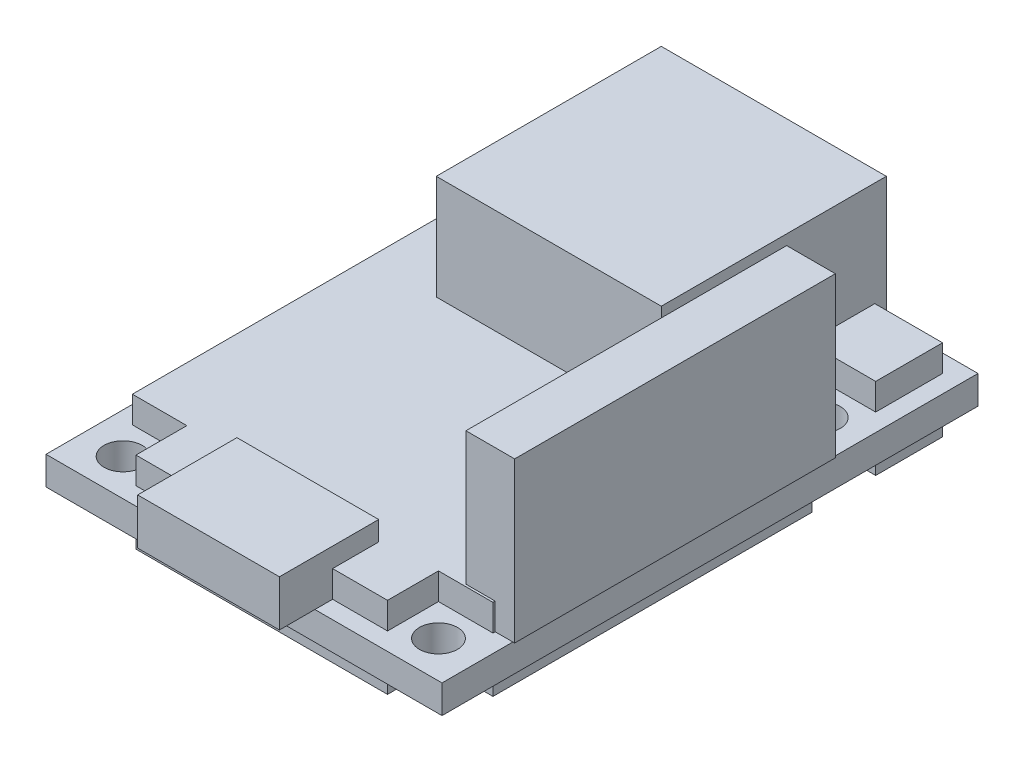
from build123d import *

# Parameters (mm, degrees)
SKETCH1_W               = 22.35
SKETCH1_H               = 30.25
BOSS_EXTRUDE1_DEPTH     = 0.8
SKETCH2_R               = 1.075
CUT_EXTRUDE1_DEPTH      = 1.8
CUT_EXTRUDE1_DEPTH_BACK = 1.8
BOSS_EXTRUDE2_DEPTH     = 2.3
SKETCH4_W               = 8
SKETCH4_H               = 5.6
BOSS_EXTRUDE3_DEPTH     = 2.6
SKETCH5_W               = 12.7
SKETCH5_H               = 12.7
BOSS_EXTRUDE4_DEPTH     = 7.4
SKETCH6_W               = 2.75
SKETCH6_H               = 18.1
BOSS_EXTRUDE5_DEPTH     = 9


with BuildPart() as part:
    # Sketch1 → Boss-Extrude1 (new body, symmetric)
    with BuildSketch(Plane(origin=(0, 0, 0), x_dir=(1, 0, 0), z_dir=(0, 1, 0))):
        Rectangle(SKETCH1_W, SKETCH1_H)
    extrude(amount=BOSS_EXTRUDE1_DEPTH, both=True)

    # Sketch2 → Cut-Extrude1 (cut, two sides)
    with BuildSketch(Plane(origin=(0, 0, 0), x_dir=(1, 0, 0), z_dir=(0, 1, 0))) as cut_extrude1_sk:
        with Locations((8.9, 8.55)):
            Circle(SKETCH2_R)
        with Locations((8.9, -13.05)):
            Circle(SKETCH2_R)
        with Locations((-8.9, 8.55)):
            Circle(SKETCH2_R)
        with Locations((-8.9, -13.05)):
            Circle(SKETCH2_R)
    extrude(amount=CUT_EXTRUDE1_DEPTH, mode=Mode.SUBTRACT)
    extrude(cut_extrude1_sk.sketch, amount=-CUT_EXTRUDE1_DEPTH_BACK, mode=Mode.SUBTRACT)

    # Sketch3 → Boss-Extrude2 (add, symmetric)
    with BuildSketch(Plane(origin=(0, 0, 0), x_dir=(1, 0, 0), z_dir=(0, 1, 0))):
        Polygon((-10.175, 6.75), (-7.1, 6.75), (-7.1, 10.35), (-10.175, 10.35), (-10.175, 14.125), (10.175, 14.125), (10.175, 10.35), (7.1, 10.35), (7.1, 6.75), (10.175, 6.75), (10.175, -2.25), (10.175, -11.25), (7.1, -11.25), (7.1, -14.125), (-7.1, -14.125), (-7.1, -11.25), (-10.175, -11.25), (-10.175, -2.25), align=None)
    extrude(amount=BOSS_EXTRUDE2_DEPTH, both=True)

    # Sketch4 → Boss-Extrude3 (add)
    with BuildSketch(Plane(origin=(0, 0.8, 0), x_dir=(1, 0, 0), z_dir=(0, 1, 0))):
        with Locations((0, -14.325)):
            Rectangle(SKETCH4_W, SKETCH4_H)
    extrude(amount=BOSS_EXTRUDE3_DEPTH)

    # Sketch5 → Boss-Extrude4 (add)
    with BuildSketch(Plane(origin=(0, 0.8, 0), x_dir=(1, 0, 0), z_dir=(0, 1, 0))):
        with Locations((0, 8.425)):
            Rectangle(SKETCH5_W, SKETCH5_H)
    extrude(amount=BOSS_EXTRUDE4_DEPTH)

    # Sketch6 → Boss-Extrude5 (add)
    with BuildSketch(Plane(origin=(0, 0.8, 0), x_dir=(1, 0, 0), z_dir=(0, 1, 0))):
        with Locations((9.9, -2.075)):
            Rectangle(SKETCH6_W, SKETCH6_H)
    extrude(amount=BOSS_EXTRUDE5_DEPTH)


solid = part.part
